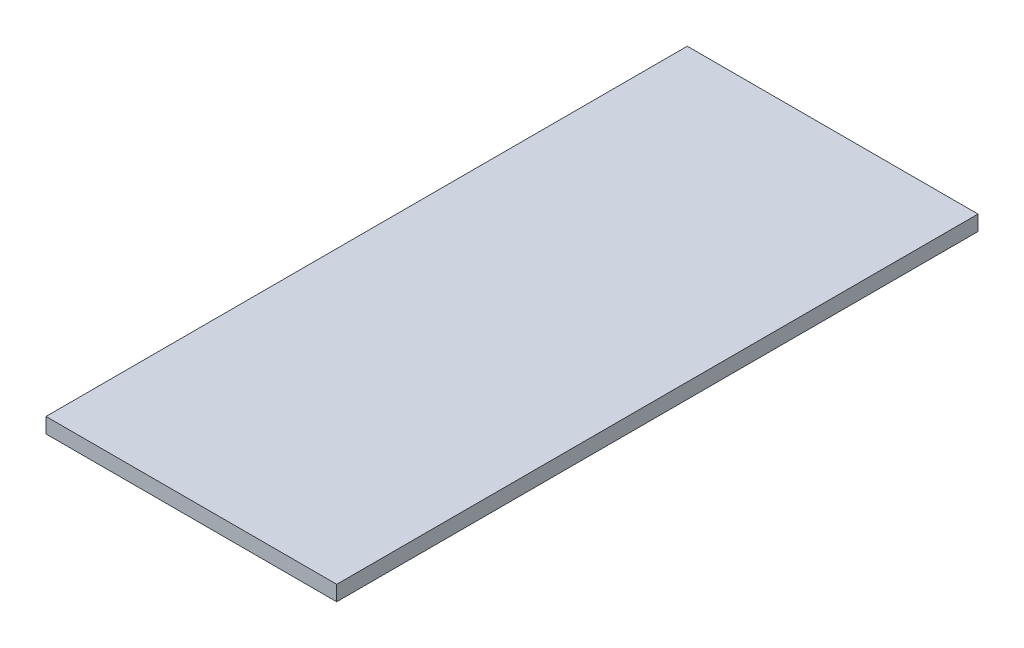
from build123d import *

# Parameters (mm, degrees)
SKETCH_1_W      = 345
SKETCH_1_H      = 761
EXTRUDE_1_DEPTH = 18


with BuildPart() as part:
    # Эскиз1 → Бобышка-Вытянуть1 (new body)
    with BuildSketch(Plane(origin=(0, 0, 0), x_dir=(1, 0, 0), z_dir=(0, 1, 0))):
        Rectangle(SKETCH_1_W, SKETCH_1_H)
    extrude(amount=EXTRUDE_1_DEPTH)


solid = part.part
